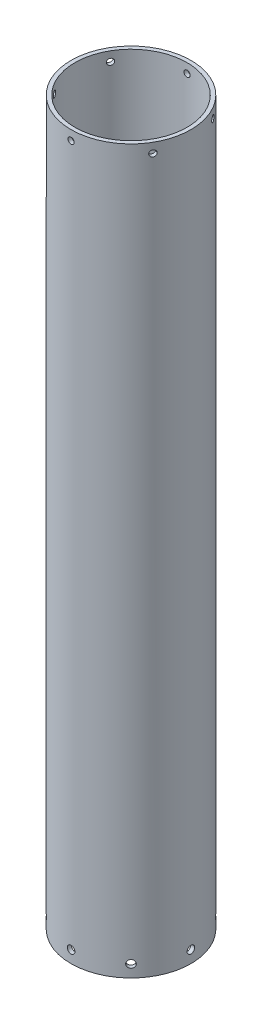
from build123d import *

# Parameters (mm, degrees)
SKETCH2_R           = 19.25
SKETCH2_R_2         = 18
BOSS_EXTRUDE1_DEPTH = 231.82
SKETCH3_R           = 1.205
CUT_EXTRUDE2_DEPTH  = 231.82
CIRPATTERN3_COUNT   = 8
SKETCH4_R           = 0.991990711
CUT_EXTRUDE3_DEPTH  = 231.82
CIRPATTERN4_COUNT   = 6


with BuildPart() as part:
    # Sketch2 → Boss-Extrude1 (new body)
    with BuildSketch(Plane(origin=(0, 0, 0), x_dir=(1, 0, 0), z_dir=(0, 1, 0))):
        Circle(SKETCH2_R)
        Circle(SKETCH2_R_2, mode=Mode.SUBTRACT)
    extrude(amount=BOSS_EXTRUDE1_DEPTH)

    # Sketch3 → Cut-Extrude2 (cut)
    with BuildSketch(Plane.XY):
        with Locations((0, 3.92)):
            Circle(SKETCH3_R)
    cut_extrude2 = extrude(amount=-CUT_EXTRUDE2_DEPTH, mode=Mode.SUBTRACT)

    # CirPattern3: Cut-Extrude2 ×8 about axis
    cirpattern3_axis = Axis((0, 231.82, 0), (0, -1, 0))
    for i in range(1, CIRPATTERN3_COUNT):
        add(cut_extrude2.rotate(cirpattern3_axis, i * 360 / CIRPATTERN3_COUNT), mode=Mode.SUBTRACT)

    # Sketch4 → Cut-Extrude3 (cut)
    with BuildSketch(Plane.XY):
        with Locations((0, 228.73)):
            Circle(SKETCH4_R)
    cut_extrude3 = extrude(amount=CUT_EXTRUDE3_DEPTH, mode=Mode.SUBTRACT)

    # CirPattern4: Cut-Extrude3 ×6 about axis
    cirpattern4_axis = Axis((0, 231.82, 0), (0, -1, 0))
    for i in range(1, CIRPATTERN4_COUNT):
        add(cut_extrude3.rotate(cirpattern4_axis, i * 360 / CIRPATTERN4_COUNT), mode=Mode.SUBTRACT)


solid = part.part
